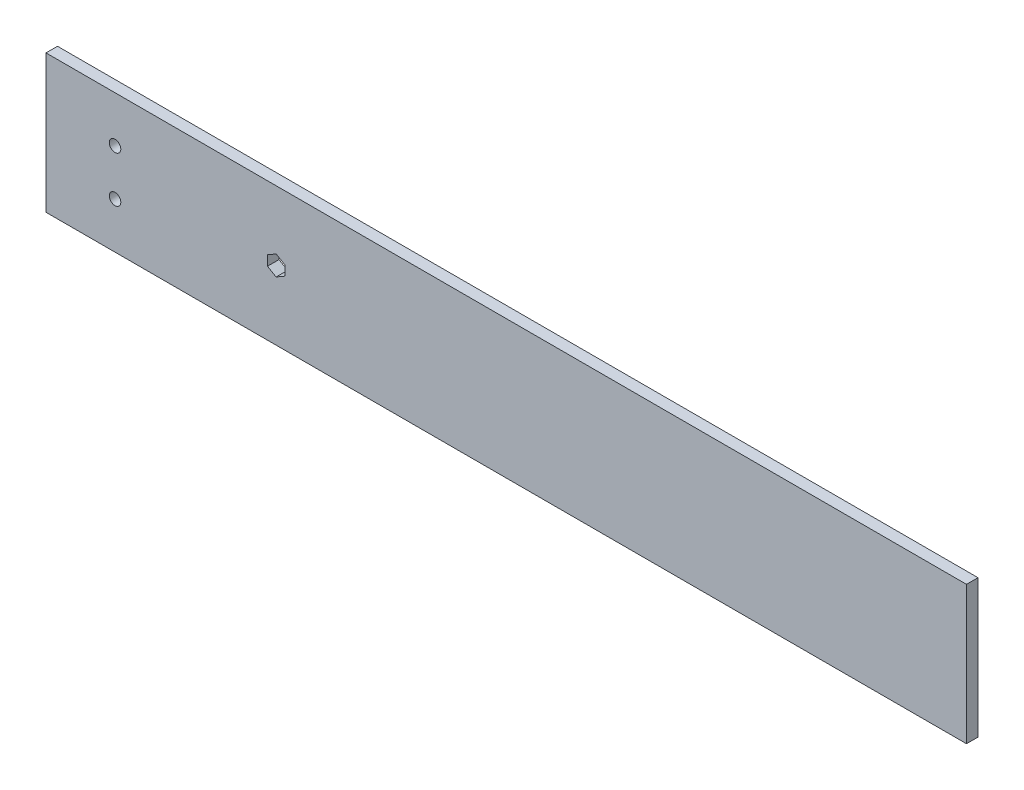
from build123d import *

# Parameters (mm, degrees)
SKETCH1_W           = 508
SKETCH1_H           = 76.2
BOSS_EXTRUDE1_DEPTH = 6.35
CUT_EXTRUDE6_DEPTH  = 7.35
SKETCH6_R           = 3.175
CUT_EXTRUDE7_DEPTH  = 7.35


with BuildPart() as part:
    # Sketch1 → Boss-Extrude1 (new body)
    with BuildSketch(Plane.XY):
        with Locations((254, 38.1)):
            Rectangle(SKETCH1_W, SKETCH1_H)
    extrude(amount=BOSS_EXTRUDE1_DEPTH)

    # Sketch4 → Cut-Extrude6 (cut, through all)
    with BuildSketch(Plane.XY.offset(6.35)):
        Polygon((127, 43.5991), (122.237639702, 40.84955), (122.237639702, 35.35045), (127, 32.6009), (131.762360298, 35.35045), (131.762360298, 40.84955), align=None)
    extrude(amount=-CUT_EXTRUDE6_DEPTH, mode=Mode.SUBTRACT)

    # Sketch6 → Cut-Extrude7 (cut, through all)
    with BuildSketch(Plane.XY.offset(6.35)):
        with Locations((38.1, 50.8)):
            Circle(SKETCH6_R)
        with Locations((38.1, 25.4)):
            Circle(SKETCH6_R)
    extrude(amount=-CUT_EXTRUDE7_DEPTH, mode=Mode.SUBTRACT)


solid = part.part
